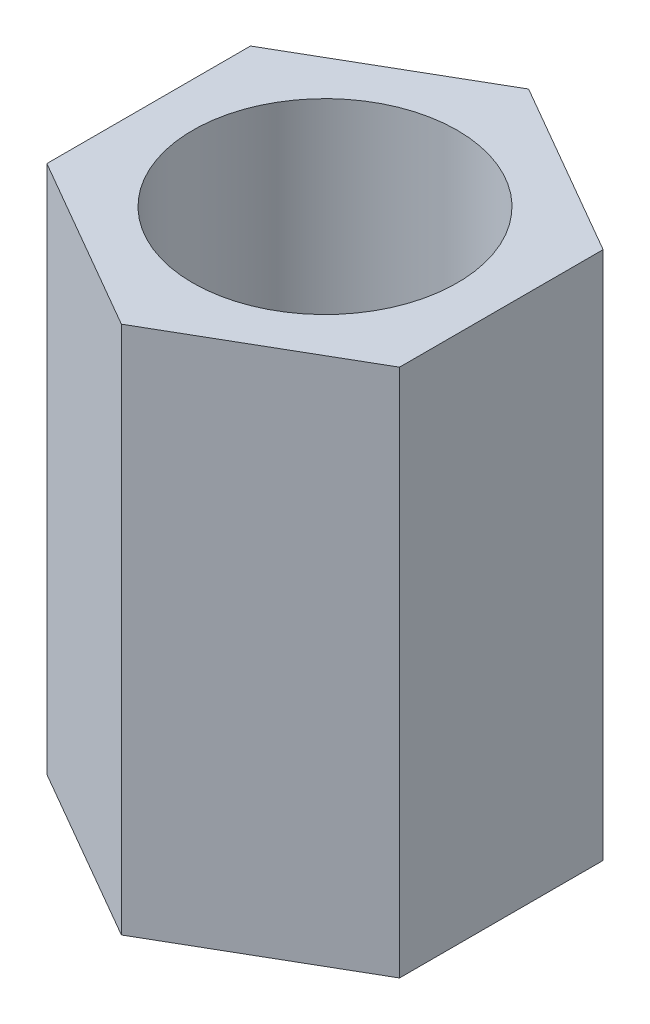
from build123d import *

# Parameters (mm, degrees)
SKETCH1_R           = 1.5
BOSS_EXTRUDE1_DEPTH = 3


with BuildPart() as part:
    # Sketch1 → Boss-Extrude1 (new body, symmetric)
    with BuildSketch(Plane(origin=(0, 0, 0), x_dir=(1, 0, 0), z_dir=(0, 1, 0))):
        Polygon((2, 1.154700538), (0, 2.309401077), (-2, 1.154700538), (-2, -1.154700538), (0, -2.309401077), (2, -1.154700538), align=None)
        Circle(SKETCH1_R, mode=Mode.SUBTRACT)
    extrude(amount=BOSS_EXTRUDE1_DEPTH, both=True)


solid = part.part
